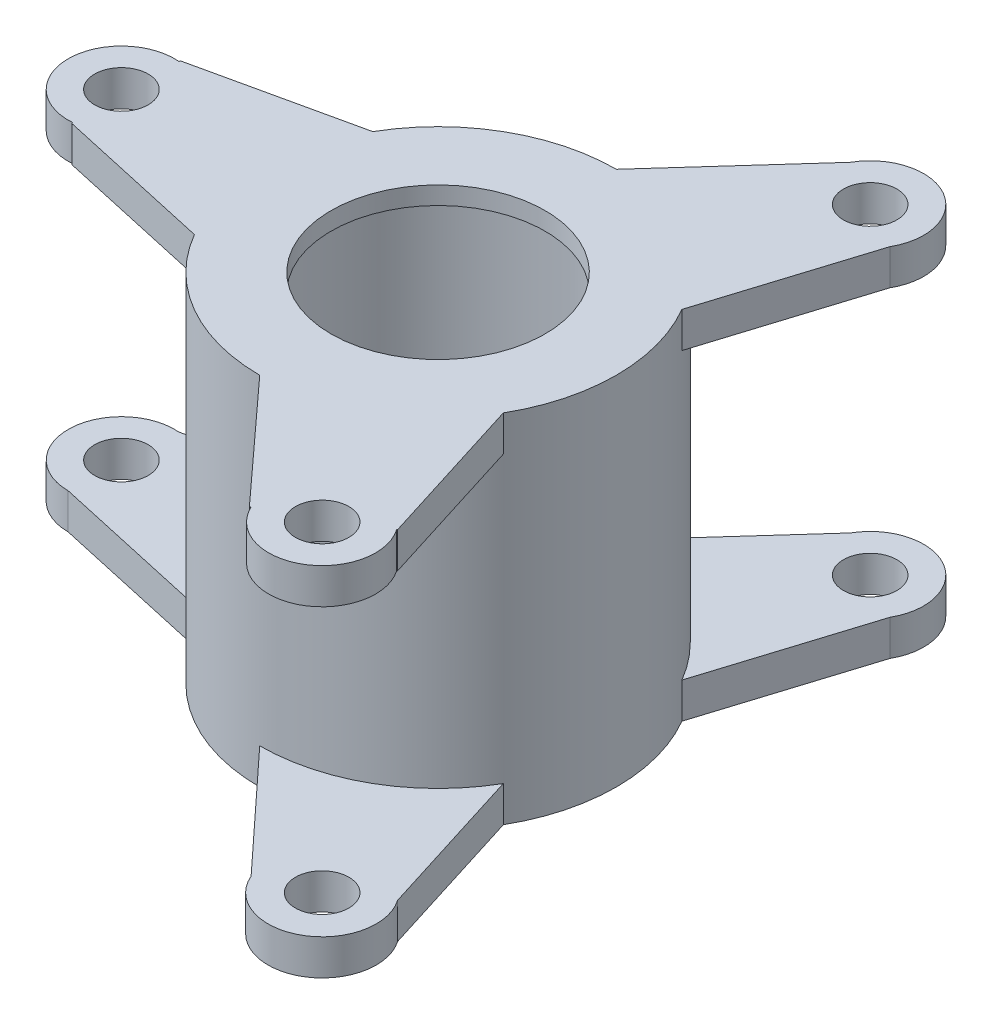
from build123d import *

# Parameters (mm, degrees)
SKETCH1_R            = 50
SKETCH1_R_2          = 40
BOSS_EXTRUDE2_DEPTH  = 100
SKETCH4_R            = 40
SKETCH4_R_2          = 30
BOSS_EXTRUDE5_DEPTH  = 5
SKETCH2_R            = 40
BOSS_EXTRUDE6_DEPTH  = 5
SKETCH5_R            = 35
CUT_EXTRUDE1_DEPTH   = 5
SKETCH8_R            = 15
SKETCH8_R_2          = 7.5
SKETCH8_R_3          = 14.918013771
BOSS_EXTRUDE9_DEPTH  = 10
BOSS_EXTRUDE13_DEPTH = 10
SKETCH18_R           = 7.5
CUT_EXTRUDE5_DEPTH   = 10


with BuildPart() as part:
    # Sketch1 → Boss-Extrude2 (new body)
    with BuildSketch(Plane(origin=(0, 0, 0), x_dir=(1, 0, 0), z_dir=(0, 1, 0))):
        with Locations(Location((0, 0, 0), (0, 0, 270))):
            Circle(SKETCH1_R)
        with Locations(Location((0, 0, 0), (0, 0, 270))):
            Circle(SKETCH1_R_2, mode=Mode.SUBTRACT)
    extrude(amount=BOSS_EXTRUDE2_DEPTH)

    # Sketch4 → Boss-Extrude5 (add)
    with BuildSketch(Plane(origin=(0, 100, 0), x_dir=(1, 0, 0), z_dir=(0, 1, 0))):
        with Locations(Location((0, 0, 0), (0, 0, 270))):
            Circle(SKETCH4_R)
        with Locations(Location((0, 0, 0), (0, 0, 270))):
            Circle(SKETCH4_R_2, mode=Mode.SUBTRACT)
    extrude(amount=-BOSS_EXTRUDE5_DEPTH)

    # Sketch2 → Boss-Extrude6 (add)
    with BuildSketch(Plane(origin=(0, 0, 0), x_dir=(1, 0, 0), z_dir=(0, 1, 0))):
        with Locations(Location((0, 0, 0), (0, 0, 270))):
            Circle(SKETCH2_R)
    extrude(amount=BOSS_EXTRUDE6_DEPTH)

    # Sketch5 → Cut-Extrude1 (cut)
    with BuildSketch(Plane.XZ):
        with Locations(Location((0, 0, 0), (0, 0, 270))):
            Circle(SKETCH5_R)
    extrude(amount=-CUT_EXTRUDE1_DEPTH, mode=Mode.SUBTRACT)

    # Sketch8 → Boss-Extrude9 (add)
    with BuildSketch(Plane(origin=(0, 100, 0), x_dir=(1, 0, 0), z_dir=(0, 1, 0))):
        with BuildLine():
            ThreePointArc((-43.301270189, -25), (-50, 0), (-43.301270189, 25))
            Line((-43.301270189, 25), (-87.465711201, 15.208979149))
            ThreePointArc((-87.465711201, 15.208979149), (-87.49541557, 15.037151885), (-87.524782384, 14.865266608))
            ThreePointArc((-87.524782384, 14.865266608), (-77.795338999, 10.095768004), (-73.860157435, 0))
            ThreePointArc((-73.860157435, 0), (-77.795338999, -10.095768004), (-87.524782384, -14.865266608))
            ThreePointArc((-87.524782384, -14.865266608), (-87.49541557, -15.037151885), (-87.465711201, -15.208979149))
            Line((-87.465711201, -15.208979149), (-43.301270189, -25))
        make_face()
        with BuildLine():
            ThreePointArc((0, 50), (24.918582465, 43.348174678), (43.207002617, 25.162569917))
            Line((43.207002617, 25.162569917), (57.131969376, 69.588086322))
            ThreePointArc((57.131969376, 69.588086322), (36.661274001, 64.024757205), (31.097944884, 84.49545258))
            Line((31.097944884, 84.49545258), (0, 50))
        make_face()
        with Locations((44.11495713, 77.041769451)):
            Circle(SKETCH8_R)
        with Locations(Location((44.11495713, 77.041769451, 0), (0, 0, 270))):
            Circle(SKETCH8_R_2, mode=Mode.SUBTRACT)
        with Locations((44.389085603, -76.884151566)):
            Circle(SKETCH8_R)
        with Locations(Location((44.389085603, -76.884151566, 0), (0, 0, 270))):
            Circle(SKETCH8_R_2, mode=Mode.SUBTRACT)
        with BuildLine():
            Line((56.839616952, -68.196932683), (43.301270189, -25))
            ThreePointArc((43.301270189, -25), (25, -43.301270189), (0, -50))
            Line((0, -50), (30.482572388, -83.380911864))
            ThreePointArc((30.482572388, -83.380911864), (30.64711663, -83.32057324), (30.811541435, -83.259909903))
            ThreePointArc((30.811541435, -83.259909903), (36.889085603, -63.893770509), (56.699426375, -68.313532564))
            ThreePointArc((56.699426375, -68.313532564), (56.7695516, -68.255268616), (56.839616952, -68.196932683))
        make_face()
        with Locations((-88.778171206, 0)):
            Circle(SKETCH8_R_3)
        with Locations(Location((-88.778171206, 0, 0), (0, 0, 270))):
            Circle(SKETCH8_R_2, mode=Mode.SUBTRACT)
    extrude(amount=-BOSS_EXTRUDE9_DEPTH)

    # Sketch17 → Boss-Extrude13 (add)
    with BuildSketch(Plane(origin=(0, 0, 0), x_dir=(-1, 0, 0), z_dir=(0, -1, 0))):
        with BuildLine():
            Line((43.301270189, -25), (88.778171206, -14.918013771))
            ThreePointArc((88.778171206, -14.918013771), (103.682992353, 0.627249114), (87.524782384, 14.865266608))
            Line((87.524782384, 14.865266608), (43.207002617, 25.162569917))
            ThreePointArc((43.207002617, 25.162569917), (49.999911712, 0.093961898), (43.301270189, -25))
        make_face()
        with BuildLine():
            ThreePointArc((-43.207002617, 25.162569917), (-24.918582465, 43.348174678), (0, 50))
            Line((0, 50), (-31.097944884, 84.49545258))
            ThreePointArc((-31.097944884, 84.49545258), (-51.568640259, 90.058781697), (-57.131969376, 69.588086322))
            Line((-57.131969376, 69.588086322), (-43.207002617, 25.162569917))
        make_face()
        with BuildLine():
            Line((-30.426057059, -82.843793895), (0, -50))
            ThreePointArc((0, -50), (-25, -43.301270189), (-43.301270189, -25))
            Line((-43.301270189, -25), (-56.839616952, -68.196932683))
            ThreePointArc((-56.839616952, -68.196932683), (-51.75145939, -90.161160078), (-30.426057059, -82.843793895))
        make_face()
    extrude(amount=-BOSS_EXTRUDE13_DEPTH)

    # Sketch18 → Cut-Extrude5 (cut)
    with BuildSketch(Plane.XZ):
        with Locations(Location((-88.778171206, 0, 0), (0, 0, 90))):
            Circle(SKETCH18_R)
        with Locations(Location((44.389085603, 76.884151566, 0), (0, 0, 90))):
            Circle(SKETCH18_R)
        with Locations(Location((44.11495713, -77.041769451, 0), (0, 0, 90))):
            Circle(SKETCH18_R)
    extrude(amount=-CUT_EXTRUDE5_DEPTH, mode=Mode.SUBTRACT)


solid = part.part
